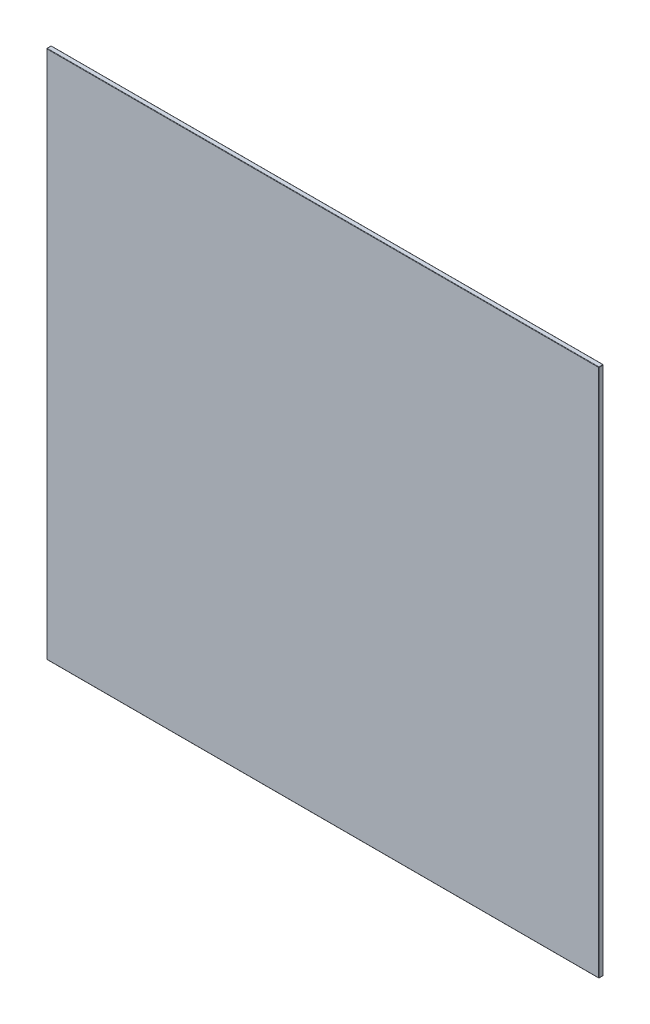
from build123d import *

# Parameters (mm, degrees)
SKETCH1_W           = 360
SKETCH1_H           = 345
BOSS_EXTRUDE1_DEPTH = 3
FILLET1_R           = 0.25


with BuildPart() as part:
    # Sketch1 → Boss-Extrude1 (new body)
    with BuildSketch(Plane.XY):
        Rectangle(SKETCH1_W, SKETCH1_H)
    extrude(amount=BOSS_EXTRUDE1_DEPTH)

    # Fillet1
    fillet1_edges = [part.edges().sort_by_distance(p)[0] for p in [
        (-180, 0, 3),
        (0, -172.5, 3),
        (180, 0, 3),
        (0, -172.5, 0),
        (-180, 0, 0),
        (0, 172.5, 0),
        (180, 0, 0),
        (0, 172.5, 3),
        (180, -172.5, 1.5),
        (-180, -172.5, 1.5),
        (-180, 172.5, 1.5),
        (180, 172.5, 1.5),
    ]]
    fillet(fillet1_edges, radius=FILLET1_R)


solid = part.part
